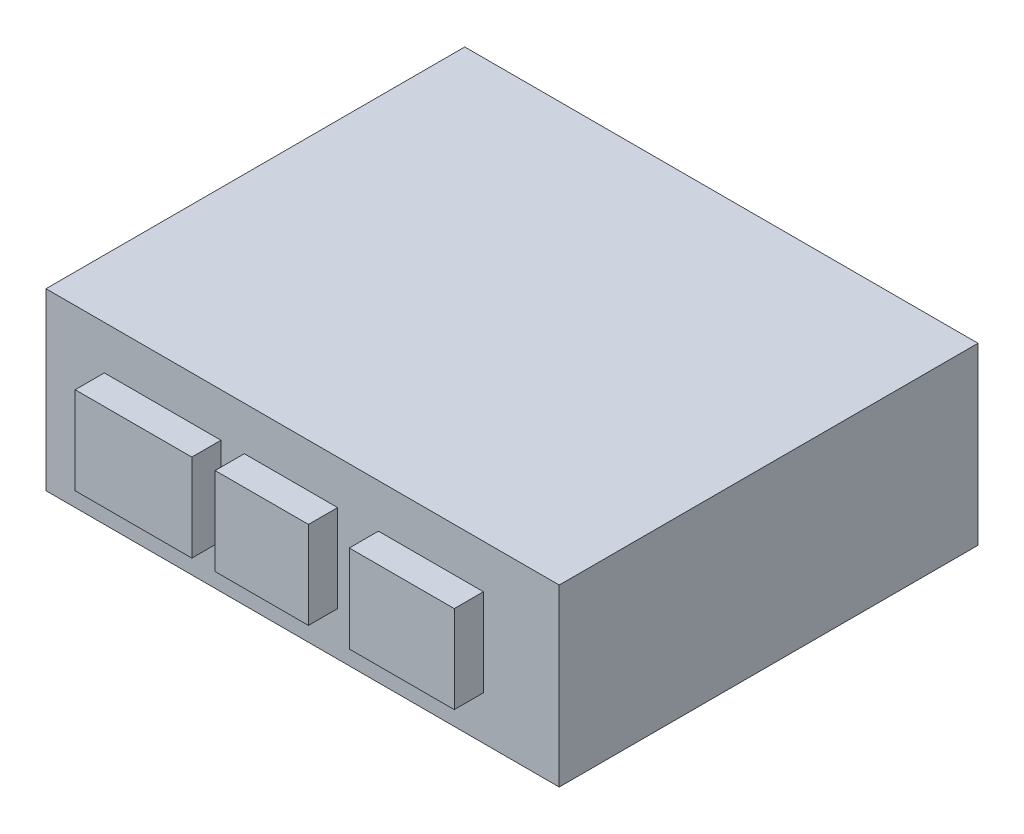
from build123d import *

# Parameters (mm, degrees)
SKETCH1_W           = 88
SKETCH1_H           = 71.8
BOSS_EXTRUDE1_DEPTH = 30
SKETCH2_W           = 20
SKETCH2_H           = 15
SKETCH2_W_2         = 16
SKETCH2_W_3         = 18
BOSS_EXTRUDE2_DEPTH = 5


with BuildPart() as part:
    # Sketch1 → Boss-Extrude1 (new body)
    with BuildSketch(Plane(origin=(0, 0, 0), x_dir=(1, 0, 0), z_dir=(0, 1, 0))):
        Rectangle(SKETCH1_W, SKETCH1_H)
    extrude(amount=BOSS_EXTRUDE1_DEPTH)

    # Sketch2 → Boss-Extrude2 (add)
    with BuildSketch(Plane.XY.offset(35.9)):
        with Locations((-24, 15)):
            Rectangle(SKETCH2_W, SKETCH2_H)
        with Locations((-2, 15)):
            Rectangle(SKETCH2_W_2, SKETCH2_H)
        with Locations((22, 15)):
            Rectangle(SKETCH2_W_3, SKETCH2_H)
    extrude(amount=BOSS_EXTRUDE2_DEPTH)


solid = part.part
